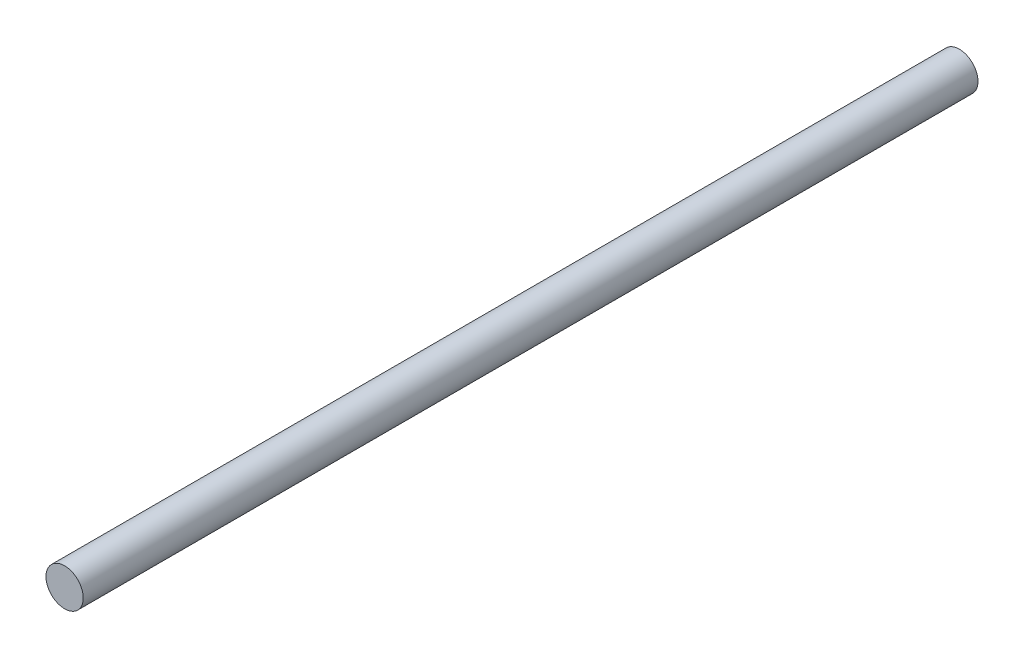
from build123d import *

# Parameters (mm, degrees)
BOSS_EXTRUDE1_DEPTH      = 457.2
BOSS_EXTRUDE1_DEPTH_BACK = 457.2
SKETCH3_R                = 19.05


with BuildPart() as part:
    # Sketch3 → Boss-Extrude1 (new, two sides: drawn at the far end of the back side and taken through both)
    with BuildSketch(Plane.XY.offset(-BOSS_EXTRUDE1_DEPTH_BACK)):
        Circle(SKETCH3_R)
    extrude(amount=BOSS_EXTRUDE1_DEPTH + BOSS_EXTRUDE1_DEPTH_BACK)


solid = part.part
